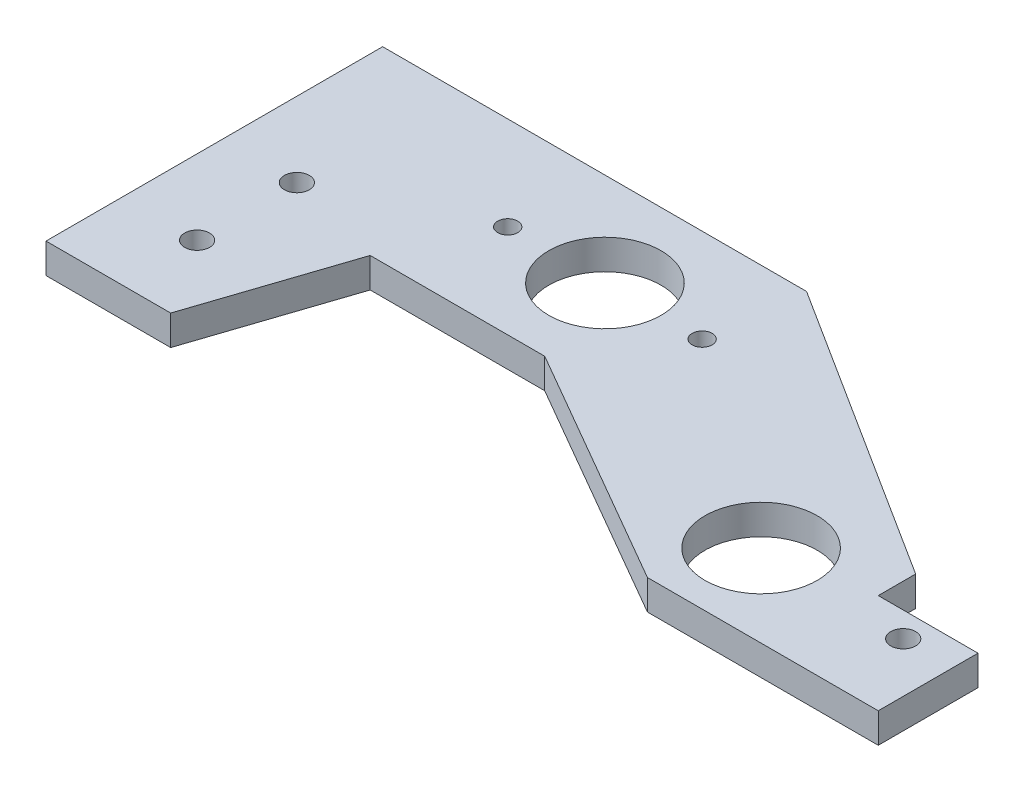
from build123d import *

# Parameters (mm, degrees)
SKETCH1_R           = 14.2875
BOSS_EXTRUDE1_DEPTH = 7.62
SKETCH2_R           = 14.2875
SKETCH2_R_2         = 2.5527
CUT_EXTRUDE1_DEPTH  = 8.62
SKETCH5_W           = 25.4
SKETCH5_H           = 25.4
SKETCH5_R           = 3.175
BOSS_EXTRUDE3_DEPTH = 7.62
BOSS_EXTRUDE4_DEPTH = 7.62
SKETCH7_R           = 3.175
CUT_EXTRUDE2_DEPTH  = 8.62
CUT_EXTRUDE3_DEPTH  = 7.62


with BuildPart() as part:
    # Sketch1 → Boss-Extrude1 (new body)
    with BuildSketch(Plane(origin=(0, 0, 0), x_dir=(1, 0, 0), z_dir=(0, 1, 0))):
        Polygon((-76.2, 14.749121283), (-14.331263069, -20.970810639), (25.4, -20.970810639), (25.4, 13.954189361), (-50.8, 62.374121283), (-152.4, 62.374121283), (-152.4, 14.749121283), align=None)
        Circle(SKETCH1_R, mode=Mode.SUBTRACT)
    extrude(amount=BOSS_EXTRUDE1_DEPTH)

    # Sketch2 → Cut-Extrude1 (cut, through all)
    with BuildSketch(Plane(origin=(0, 7.62, 0), x_dir=(1, 0, 0), z_dir=(0, 1, 0))):
        with Locations((-78.335649741, 38.561621283)):
            Circle(SKETCH2_R)
        with Locations((-103.087949741, 38.561621283)):
            Circle(SKETCH2_R_2)
        with Locations((-53.583349741, 38.561621283)):
            Circle(SKETCH2_R_2)
    extrude(amount=-CUT_EXTRUDE1_DEPTH, mode=Mode.SUBTRACT)

    # Sketch5 → Boss-Extrude3 (add)
    with BuildSketch(Plane(origin=(0, 7.62, 0), x_dir=(1, 0, 0), z_dir=(0, 1, 0))):
        with Locations((38.1, -8.270810639)):
            Rectangle(SKETCH5_W, SKETCH5_H)
        with Locations((38.1, -1.920810639)):
            Circle(SKETCH5_R, mode=Mode.SUBTRACT)
    extrude(amount=-BOSS_EXTRUDE3_DEPTH)

    # Sketch6 → Boss-Extrude4 (add)
    with BuildSketch(Plane(origin=(0, 7.62, 0), x_dir=(1, 0, 0), z_dir=(0, 1, 0))):
        Polygon((-152.4, -23.350878717), (-127, -23.350878717), (-114.3, 14.749121283), (-152.4, 14.749121283), (-152.4, 62.374121283), (-158.75, 62.374121283), (-158.75, -23.350878717), align=None)
    extrude(amount=-BOSS_EXTRUDE4_DEPTH)

    # Sketch7 → Cut-Extrude2 (cut, through all)
    with BuildSketch(Plane(origin=(0, 7.62, 0), x_dir=(1, 0, 0), z_dir=(0, 1, 0))):
        with Locations((-139.7, 21.480121283)):
            Circle(SKETCH7_R)
        with Locations((-139.7, -3.919878717)):
            Circle(SKETCH7_R)
    extrude(amount=-CUT_EXTRUDE2_DEPTH, mode=Mode.SUBTRACT)

    # Sketch10 → Cut-Extrude3 (cut)
    with BuildSketch(Plane(origin=(0, 7.62, 0), x_dir=(1, 0, 0), z_dir=(0, 1, 0))):
        Polygon((-76.2, 14.749121283), (-69.85, 14.749121283), (-7.981263069, -20.970810639), (-14.331263069, -20.970810639), align=None)
    extrude(amount=-CUT_EXTRUDE3_DEPTH, mode=Mode.SUBTRACT)


solid = part.part
